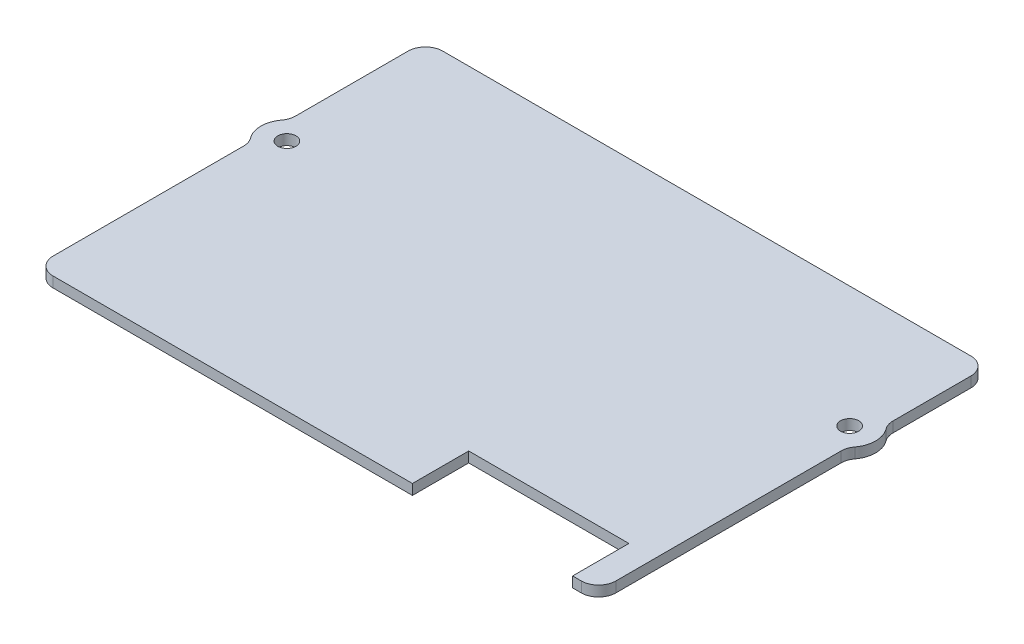
from build123d import *

# Parameters (mm, degrees)
SKETCH_1_W          = 65
SKETCH_1_H          = 45
EXTRUDE_1_DEPTH     = 1.2
FILLET_1_R          = 2
SKETCH_2_5_R        = 3
EXTRUDE_2_DEPTH     = 1.2
SKETCH_2_R          = 1.05
CUT_EXTRUDE_1_DEPTH = 80.890174615
FILLET_2_R          = 2
SKETCH_3_W          = 18.5
SKETCH_3_H          = 6.5
CUT_EXTRUDE_2_DEPTH = 80.890174615


with BuildPart() as part:
    # 草图1 → 凸台-拉伸1 (new body)
    with BuildSketch(Plane(origin=(0, 0, 0), x_dir=(1, 0, 0), z_dir=(0, 1, 0))):
        with Locations((32.5, 22.5)):
            Rectangle(SKETCH_1_W, SKETCH_1_H)
    extrude(amount=EXTRUDE_1_DEPTH)

    # 圆角1
    fillet_1_edges = [part.edges().sort_by_distance(p)[0] for p in [
        (0, 0.6, 0),
        (0, 0.6, -45),
        (65, 0.6, -45),
        (65, 0.6, 0),
    ]]
    fillet(fillet_1_edges, radius=FILLET_1_R)

    # 草图2<5> → 凸台-拉伸2 (add)
    with BuildSketch(Plane(origin=(0, 1.2, 0), x_dir=(1, 0, 0), z_dir=(0, 1, 0))):
        with Locations((63, 31)):
            Circle(SKETCH_2_5_R)
        with Locations((2, 27)):
            Circle(SKETCH_2_5_R)
    extrude(amount=-EXTRUDE_2_DEPTH)

    # 草图2 → 切除-拉伸1 (cut, through all)
    with BuildSketch(Plane(origin=(0, 1.2, 0), x_dir=(1, 0, 0), z_dir=(0, 1, 0))):
        with Locations((63, 31)):
            Circle(SKETCH_2_R)
        with Locations((2, 27)):
            Circle(SKETCH_2_R)
    extrude(amount=-CUT_EXTRUDE_1_DEPTH, mode=Mode.SUBTRACT)

    # 圆角2
    fillet_2_edges = [part.edges().sort_by_distance(p)[0] for p in [
        (65, 0.6, -28.763932023),
        (65, 0.6, -33.236067977),
        (0, 0.6, -24.763932023),
        (0, 0.6, -29.236067977),
    ]]
    fillet(fillet_2_edges, radius=FILLET_2_R)

    # 草图3 → 切除-拉伸2 (cut, through all)
    with BuildSketch(Plane(origin=(0, 1.2, 0), x_dir=(1, 0, 0), z_dir=(0, 1, 0))):
        with Locations((52.75, 3.25)):
            Rectangle(SKETCH_3_W, SKETCH_3_H)
    extrude(amount=-CUT_EXTRUDE_2_DEPTH, mode=Mode.SUBTRACT)


solid = part.part
